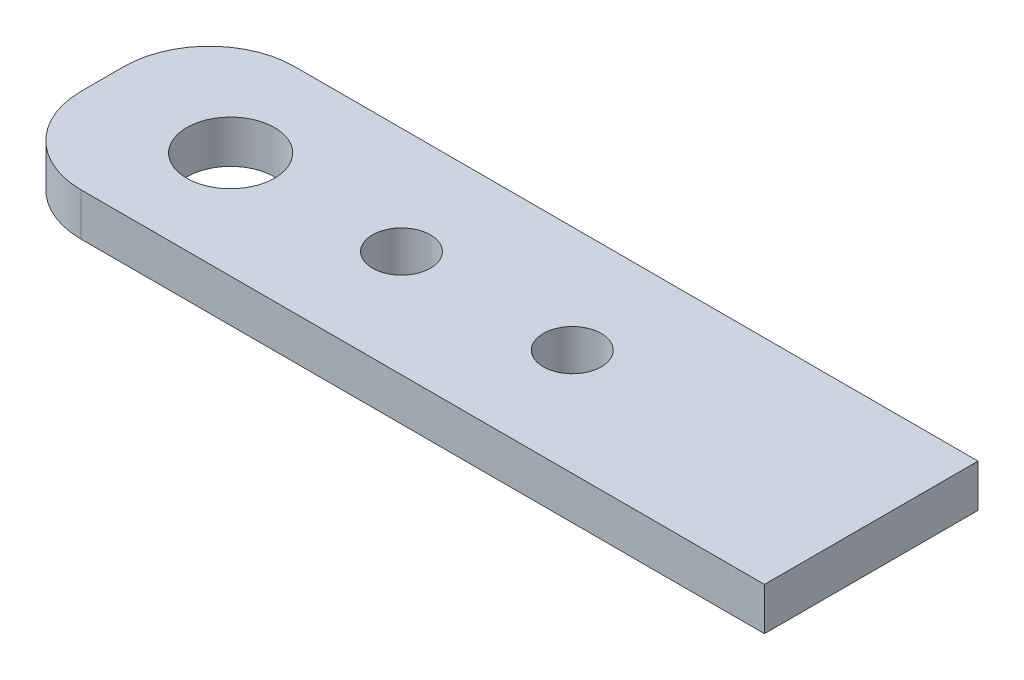
from build123d import *

# Parameters (mm, degrees)
SKETCH1_W                    = 57.15
SKETCH1_H                    = 15.875
BOSS_EXTRUDE1_DEPTH          = 3.175
F_0_257_DIAMETER_HOLE1_D     = 6.5278
FILLET1_R                    = 6.35
F_18_0_1695_DIAMETER_HOLE1_D = 4.3053


with BuildPart() as part:
    # Sketch1 → Boss-Extrude1 (new body)
    with BuildSketch(Plane(origin=(0, 0, 0), x_dir=(1, 0, 0), z_dir=(0, 1, 0))):
        Rectangle(SKETCH1_W, SKETCH1_H)
    extrude(amount=BOSS_EXTRUDE1_DEPTH)

    # F (0.257) Diameter Hole1 (through all)
    with Locations(Plane(origin=(0, 3.175, 0), x_dir=(1, 0, 0), z_dir=(0, 1, 0))):
        with Locations((-19.05, 0)):
            Hole(F_0_257_DIAMETER_HOLE1_D / 2)

    # Fillet1
    fillet1_edges = [part.edges().sort_by_distance(p)[0] for p in [
        (-28.575, 1.5875, 7.9375),
        (-28.575, 1.5875, -7.9375),
    ]]
    fillet(fillet1_edges, radius=FILLET1_R)

    # #18 (0.1695) Diameter Hole1 (through all)
    with Locations(Plane(origin=(0, 3.175, 0), x_dir=(1, 0, 0), z_dir=(0, 1, 0))):
        with Locations((-6.35, 0), (6.35, 0)):
            Hole(F_18_0_1695_DIAMETER_HOLE1_D / 2)


solid = part.part
